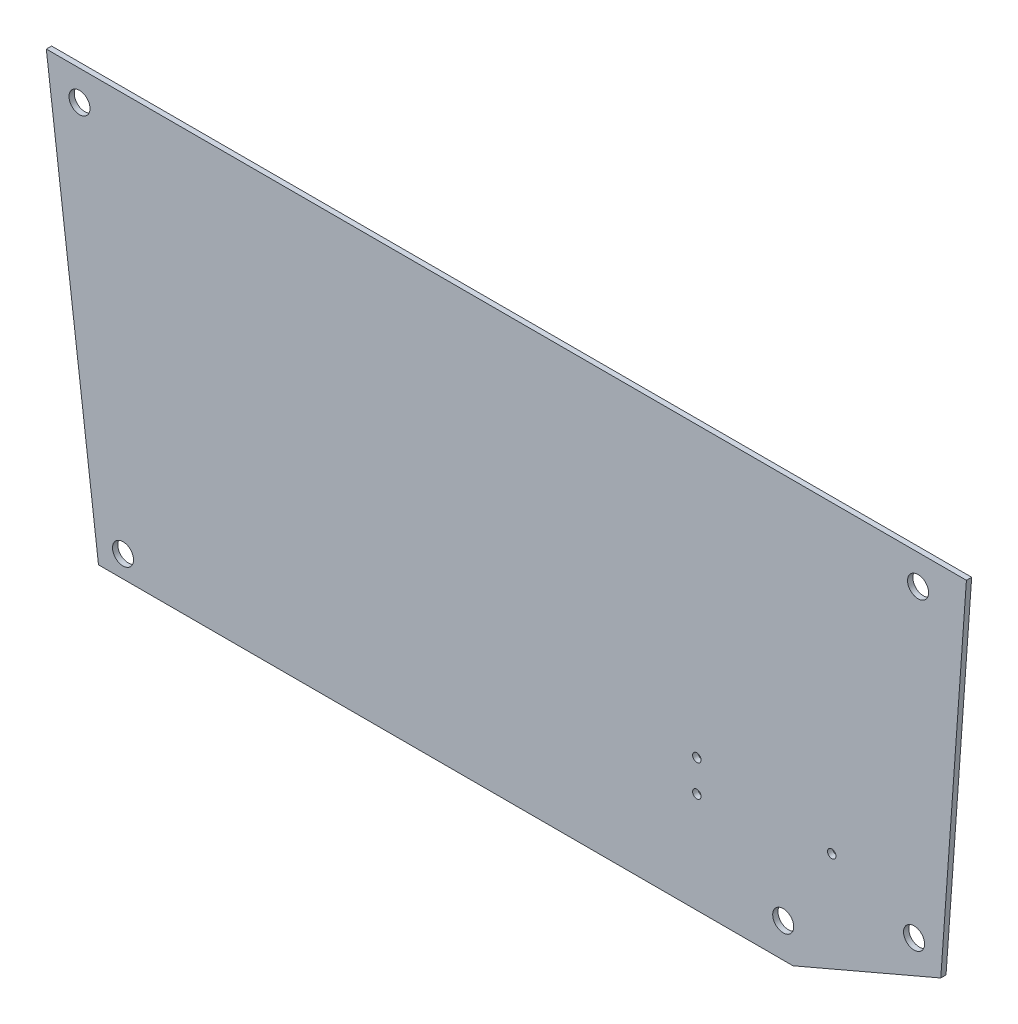
from build123d import *

# Parameters (mm, degrees)
SKETCH1_R           = 1.6
SKETCH1_R_2         = 4
BOSS_EXTRUDE1_DEPTH = 1


with BuildPart() as part:
    # Sketch1 → Boss-Extrude1 (new body, symmetric)
    with BuildSketch(Plane.XY):
        Polygon((-58.447822699, 2.25215401), (205.719516193, 2.25215401), (261.946581062, 26.347260557), (271.703456729, 162.25215401), (-78.296543271, 162.25215401), align=None)
        with Locations((169.158925411, 40.547600357)):
            Circle(SKETCH1_R, mode=Mode.SUBTRACT)
        with Locations((169.158925411, 52.547600357)):
            Circle(SKETCH1_R, mode=Mode.SUBTRACT)
        with Locations((220.457146693, 46.547600357)):
            Circle(SKETCH1_R, mode=Mode.SUBTRACT)
        with Locations((-65.674373942, 150.94432728)):
            Circle(SKETCH1_R_2, mode=Mode.SUBTRACT)
        with Locations((253.311068017, 150.94432728)):
            Circle(SKETCH1_R_2, mode=Mode.SUBTRACT)
        with Locations((251.787322425, 34.458331013)):
            Circle(SKETCH1_R_2, mode=Mode.SUBTRACT)
        with Locations((202.012846736, 15.25215401)):
            Circle(SKETCH1_R_2, mode=Mode.SUBTRACT)
        with Locations((-49.126516792, 10.545043982)):
            Circle(SKETCH1_R_2, mode=Mode.SUBTRACT)
    extrude(amount=BOSS_EXTRUDE1_DEPTH, both=True)


solid = part.part
